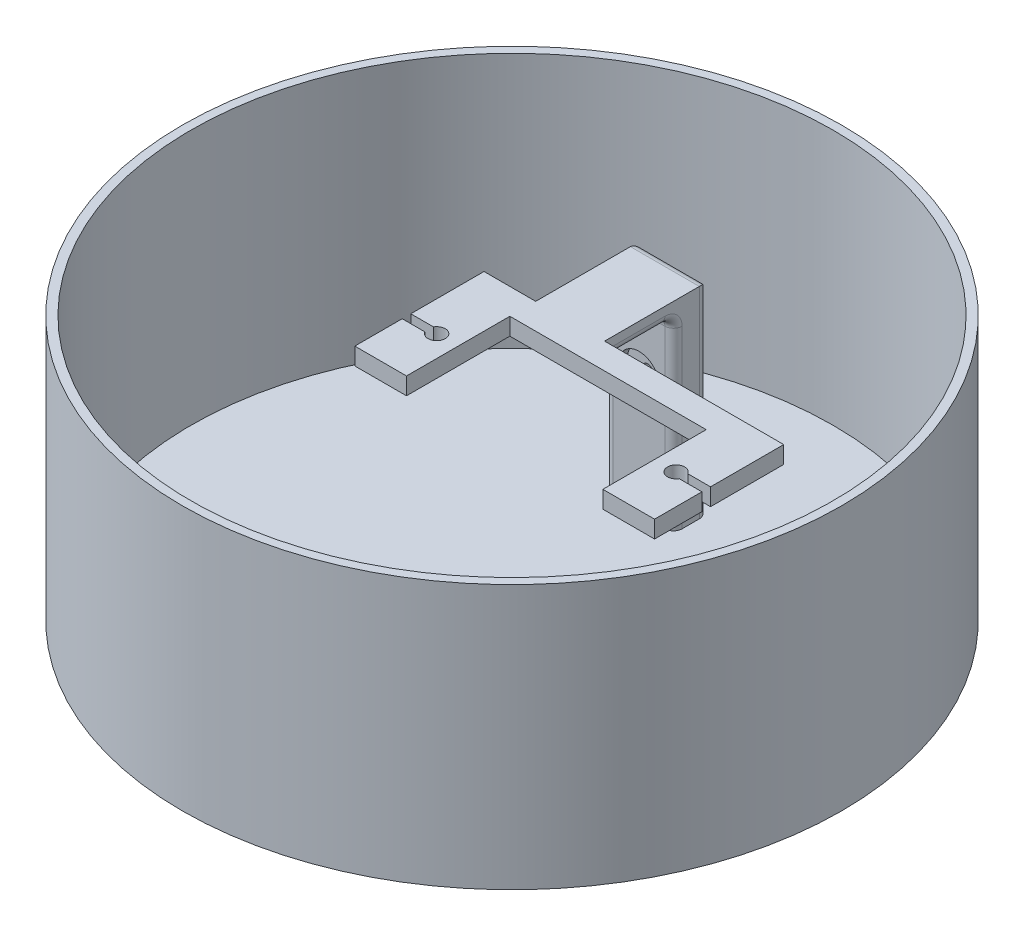
from build123d import *

# Parameters (mm, degrees)
BOSS_EXTRUDE1_DEPTH = 2
SKETCH3_W           = 8
SKETCH3_H           = 13.374853929
BOSS_EXTRUDE2_DEPTH = 4
FILLET1_R           = 1
SKETCH4_R           = 2.35
SKETCH4_R_2         = 0.6
CUT_EXTRUDE1_DEPTH  = 2
SKETCH4_4_R         = 0.6
CUT_EXTRUDE2_DEPTH  = 4
CUT_EXTRUDE3_START  = -4
SKETCH4_5_R         = 2.35
SKETCH4_5_R_2       = 0.6
CUT_EXTRUDE3_DEPTH  = 1
BOSS_EXTRUDE3_START = 10
SKETCH6_R           = 37.280765685
BOSS_EXTRUDE3_DEPTH = 1
EXTRUDE_THIN1_START = 11
SKETCH6_2_R         = 38.280765685
SKETCH6_2_R_2       = 37.280765685
EXTRUDE_THIN1_DEPTH = 30.684854
BOSS_EXTRUDE4_DEPTH = 10


with BuildPart() as part:
    # Sketch1 → Boss-Extrude1 (new body)
    with BuildSketch(Plane(origin=(0, 0, 0), x_dir=(1, 0, 0), z_dir=(0, 1, 0))):
        with BuildLine():
            Line((-11.4, -6), (-17.4, -6))
            Line((-17.4, -6), (-17.4, -0.5))
            Line((-17.4, -0.5), (-14.766025404, -0.5))
            ThreePointArc((-14.766025404, -0.5), (-12.9, 0), (-14.766025404, 0.5))
            Line((-14.766025404, 0.5), (-17.4, 0.5))
            Line((-17.4, 0.5), (-17.4, 9))
            Line((-17.4, 9), (-11.4, 9))
            Line((-11.4, 9), (-11.4, 17))
            Line((-11.4, 17), (-3.4, 17))
            Line((-3.4, 17), (-3.4, 9))
            Line((-3.4, 9), (17.4, 9))
            Line((17.4, 9), (17.4, 0.5))
            Line((17.4, 0.5), (14.766025404, 0.5))
            ThreePointArc((14.766025404, 0.5), (12.9, 0), (14.766025404, -0.5))
            Line((14.766025404, -0.5), (17.4, -0.5))
            Line((17.4, -0.5), (17.4, -6))
            Line((17.4, -6), (11.4, -6))
            Line((11.4, -6), (11.4, 6))
            Line((11.4, 6), (-11.4, 6))
            Line((-11.4, 6), (-11.4, -6))
        make_face()
    extrude(amount=BOSS_EXTRUDE1_DEPTH)

    # Sketch3 → Boss-Extrude2 (add)
    with BuildSketch(Plane(origin=(0, 0, -17), x_dir=(-1, 0, 0), z_dir=(0, 0, -1))):
        with Locations((7.4, -4.687426965)):
            Rectangle(SKETCH3_W, SKETCH3_H)
    extrude(amount=BOSS_EXTRUDE2_DEPTH)

    # Fillet1
    fillet1_edges = [part.edges().sort_by_distance(p)[0] for p in [
        (-11.4, 0, -13),
        (-7.4, 0, -17),
        (-3.4, 0, -13),
        (-3.4, -5.687426964, -17),
        (-11.4, -5.687426964, -17),
        (-3.4, -4.687426964, -21),
        (-11.4, -4.687426964, -21),
        (-7.4, 2, -21),
    ]]
    fillet(fillet1_edges, radius=FILLET1_R)

    # Sketch4 → Cut-Extrude1 (cut)
    with BuildSketch(Plane(origin=(0, 0, -21), x_dir=(-1, 0, 0), z_dir=(0, 0, -1))):
        with Locations((7.4, -7.374853929)):
            Circle(SKETCH4_R)
        with Locations((7.4, -7.374853929)):
            Circle(SKETCH4_R_2, mode=Mode.SUBTRACT)
        with Locations((7.4, -7.374853929)):
            Circle(SKETCH4_R_2)
    extrude(amount=-CUT_EXTRUDE1_DEPTH, mode=Mode.SUBTRACT)

    # Sketch4_4 → Cut-Extrude2 (cut)
    with BuildSketch(Plane(origin=(0, 0, -21), x_dir=(-1, 0, 0), z_dir=(0, 0, -1))):
        with Locations((7.4, -7.374853929)):
            Circle(SKETCH4_4_R)
    extrude(amount=-CUT_EXTRUDE2_DEPTH, mode=Mode.SUBTRACT)

    # Sketch4_5 → Cut-Extrude3 (cut)
    with BuildSketch(Plane(origin=(0, 0, -21), x_dir=(-1, 0, 0), z_dir=(0, 0, -1)).offset(CUT_EXTRUDE3_START)):
        with Locations((7.4, -7.374853929)):
            Circle(SKETCH4_5_R)
        with Locations((7.4, -7.374853929)):
            Circle(SKETCH4_5_R_2, mode=Mode.SUBTRACT)
    extrude(amount=CUT_EXTRUDE3_DEPTH, mode=Mode.SUBTRACT)



with BuildPart() as body_2:
    # Sketch6 → Boss-Extrude3 (new body)
    with BuildSketch(Plane.XZ.offset(11.374853929).offset(BOSS_EXTRUDE3_START)):
        with Locations((-5.05, 0.1)):
            Circle(SKETCH6_R)
    extrude(amount=BOSS_EXTRUDE3_DEPTH)

    # Sketch6_2 → Extrude-Thin1 (add)
    with BuildSketch(Plane.XZ.offset(11.374853929).offset(EXTRUDE_THIN1_START)):
        with Locations((-5.05, 0.1)):
            Circle(SKETCH6_2_R)
        with Locations((-5.05, 0.1)):
            Circle(SKETCH6_2_R_2, mode=Mode.SUBTRACT)
    extrude(amount=-EXTRUDE_THIN1_DEPTH)


with BuildPart() as part_1:
    add(part.part)

    add(body_2.part)  # Boss-Extrude4 merges body 2
    # Sketch7 → Boss-Extrude4 (add)
    with BuildSketch(Plane.XZ.offset(11.374853929)):
        with BuildLine():
            Line((-3.4, -20), (-3.4, -18))
            ThreePointArc((-3.4, -18), (-3.692893219, -17.292893219), (-4.4, -17))
            Line((-4.4, -17), (-10.4, -17))
            ThreePointArc((-10.4, -17), (-11.107106781, -17.292893219), (-11.4, -18))
            Line((-11.4, -18), (-11.4, -20))
            ThreePointArc((-11.4, -20), (-11.107106781, -20.707106781), (-10.4, -21))
            Line((-10.4, -21), (-4.4, -21))
            ThreePointArc((-4.4, -21), (-3.692893219, -20.707106781), (-3.4, -20))
        make_face()
    extrude(amount=BOSS_EXTRUDE4_DEPTH)


solid = part_1.part
